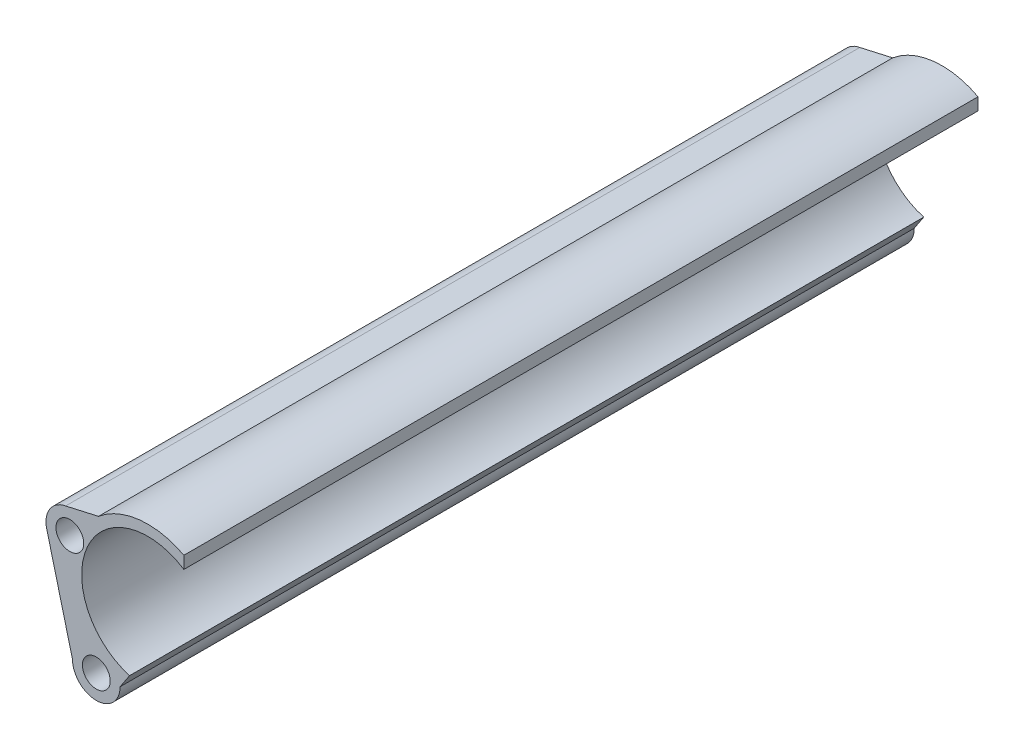
from build123d import *

# Parameters (mm, degrees)
ESQUISSE1_R        = 2.625
BOSS_EXTRU_1_DEPTH = 150


with BuildPart() as part:
    # Esquisse1 → Boss.-Extru.1 (new body)
    with BuildSketch(Plane.XY):
        with BuildLine():
            ThreePointArc((-0.79755539, 4.428758901), (-3.787637609, 2.429773929), (-4.358021192, -1.12145053))
            Line((-4.358021192, -1.12145053), (0.5, -20))
            ThreePointArc((0.5, -20), (5, -24.5), (9.5, -20))
            Line((9.5, -20), (11.28572177, -17.287605871))
            ThreePointArc((11.28572177, -17.287605871), (10.940890985, -17.183131081), (10.599214607, -17.068761049))
            ThreePointArc((10.599214607, -17.068761049), (2.237966256, -5.391928791), (10.376689651, 6.441078731))
            ThreePointArc((10.376689651, 6.441078731), (16.104400227, 7.151408987), (21.540678755, 5.212823607))
            Line((21.540678755, 5.212823607), (21.540678755, 7.531281515))
            ThreePointArc((21.540678755, 7.531281515), (13.221135766, 9.146884287), (5.419576542, 5.836198326))
            Line((5.419576542, 5.836198326), (-0.79755539, 4.428758901))
        make_face()
        with Locations((5, -20)):
            Circle(ESQUISSE1_R, mode=Mode.SUBTRACT)
        Circle(ESQUISSE1_R, mode=Mode.SUBTRACT)
    extrude(amount=BOSS_EXTRU_1_DEPTH)


solid = part.part
